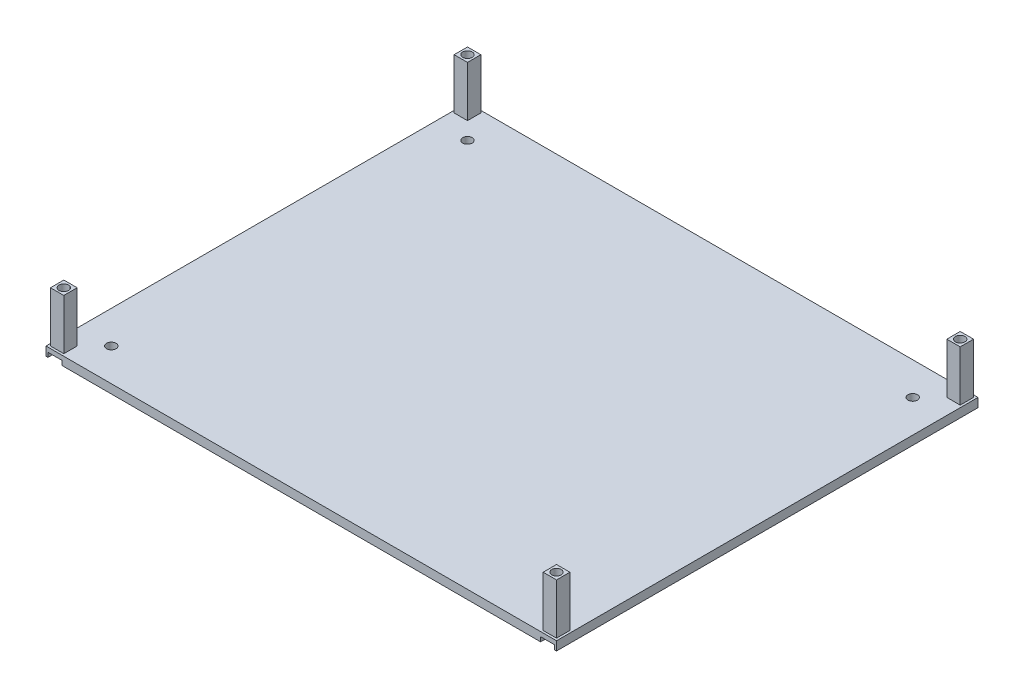
from build123d import *

# Parameters (mm, degrees)
SKETCH1_W           = 172
SKETCH1_H           = 142
SKETCH1_R           = 1.6
BOSS_EXTRUDE1_DEPTH = 3
SKETCH1_3_W         = 4.5
SKETCH1_3_H         = 4.5
SKETCH1_3_R         = 1.6
BOSS_EXTRUDE2_DEPTH = 20
SKETCH1_5_W         = 4.7
SKETCH1_5_H         = 5.35
SKETCH1_5_R         = 1.6
CUT_EXTRUDE1_DEPTH  = 1.5


with BuildPart() as part:
    # Sketch1 → Boss-Extrude1 (new body)
    with BuildSketch(Plane(origin=(0, 0, 0), x_dir=(1, 0, 0), z_dir=(0, 1, 0))):
        Rectangle(SKETCH1_W, SKETCH1_H)
        with Locations((-75, 60)):
            Circle(SKETCH1_R, mode=Mode.SUBTRACT)
        with Locations((75, 60)):
            Circle(SKETCH1_R, mode=Mode.SUBTRACT)
        with Locations((-75, -60)):
            Circle(SKETCH1_R, mode=Mode.SUBTRACT)
        with Locations((75, -60)):
            Circle(SKETCH1_R, mode=Mode.SUBTRACT)
        with Locations((-83, 68)):
            Circle(SKETCH1_R, mode=Mode.SUBTRACT)
        with Locations((83, 68)):
            Circle(SKETCH1_R, mode=Mode.SUBTRACT)
        with Locations((83, -68)):
            Circle(SKETCH1_R, mode=Mode.SUBTRACT)
        with Locations((-83, -68)):
            Circle(SKETCH1_R, mode=Mode.SUBTRACT)
    extrude(amount=BOSS_EXTRUDE1_DEPTH)

    # Sketch1_3 → Boss-Extrude2 (add)
    # profile 1 of 4: a face of its own
    with BuildSketch(Plane(origin=(0, 0, 0), x_dir=(1, 0, 0), z_dir=(0, 1, 0))):
        with Locations((-83, 68)):
            Rectangle(SKETCH1_3_W, SKETCH1_3_H)
        with Locations((-83, 68)):
            Circle(SKETCH1_3_R, mode=Mode.SUBTRACT)
    # profile 2 of 4: a face of its own
    with BuildSketch(Plane(origin=(0, 0, 0), x_dir=(1, 0, 0), z_dir=(0, 1, 0))):
        with Locations((83, 68)):
            Rectangle(SKETCH1_3_W, SKETCH1_3_H)
        with Locations((83, 68)):
            Circle(SKETCH1_3_R, mode=Mode.SUBTRACT)
    # profile 3 of 4: a face of its own
    with BuildSketch(Plane(origin=(0, 0, 0), x_dir=(1, 0, 0), z_dir=(0, 1, 0))):
        with Locations((83, -68)):
            Rectangle(SKETCH1_3_W, SKETCH1_3_H)
        with Locations((83, -68)):
            Circle(SKETCH1_3_R, mode=Mode.SUBTRACT)
    # profile 4 of 4: a face of its own
    with BuildSketch(Plane(origin=(0, 0, 0), x_dir=(1, 0, 0), z_dir=(0, 1, 0))):
        with Locations((-83, -68)):
            Rectangle(SKETCH1_3_W, SKETCH1_3_H)
        with Locations((-83, -68)):
            Circle(SKETCH1_3_R, mode=Mode.SUBTRACT)
    extrude(amount=BOSS_EXTRUDE2_DEPTH)

    # Sketch1_5 → Cut-Extrude1 (cut)
    # profile 1 of 4: a face of its own
    with BuildSketch(Plane(origin=(0, 0, 0), x_dir=(1, 0, 0), z_dir=(0, 1, 0))):
        with Locations((-83, 68.325)):
            Rectangle(SKETCH1_5_W, SKETCH1_5_H)
        with Locations((-83, 68)):
            Circle(SKETCH1_5_R, mode=Mode.SUBTRACT)
    # profile 2 of 4: a face of its own
    with BuildSketch(Plane(origin=(0, 0, 0), x_dir=(1, 0, 0), z_dir=(0, 1, 0))):
        with Locations((83, 68.325)):
            Rectangle(SKETCH1_5_W, SKETCH1_5_H)
        with Locations((83, 68)):
            Circle(SKETCH1_5_R, mode=Mode.SUBTRACT)
    # profile 3 of 4: a face of its own
    with BuildSketch(Plane(origin=(0, 0, 0), x_dir=(1, 0, 0), z_dir=(0, 1, 0))):
        with Locations((-83, -68.325)):
            Rectangle(SKETCH1_5_W, SKETCH1_5_H)
        with Locations((-83, -68)):
            Circle(SKETCH1_5_R, mode=Mode.SUBTRACT)
    # profile 4 of 4: a face of its own
    with BuildSketch(Plane(origin=(0, 0, 0), x_dir=(1, 0, 0), z_dir=(0, 1, 0))):
        with Locations((83, -68.325)):
            Rectangle(SKETCH1_5_W, SKETCH1_5_H)
        with Locations((83, -68)):
            Circle(SKETCH1_5_R, mode=Mode.SUBTRACT)
    extrude(amount=CUT_EXTRUDE1_DEPTH, mode=Mode.SUBTRACT)


solid = part.part
